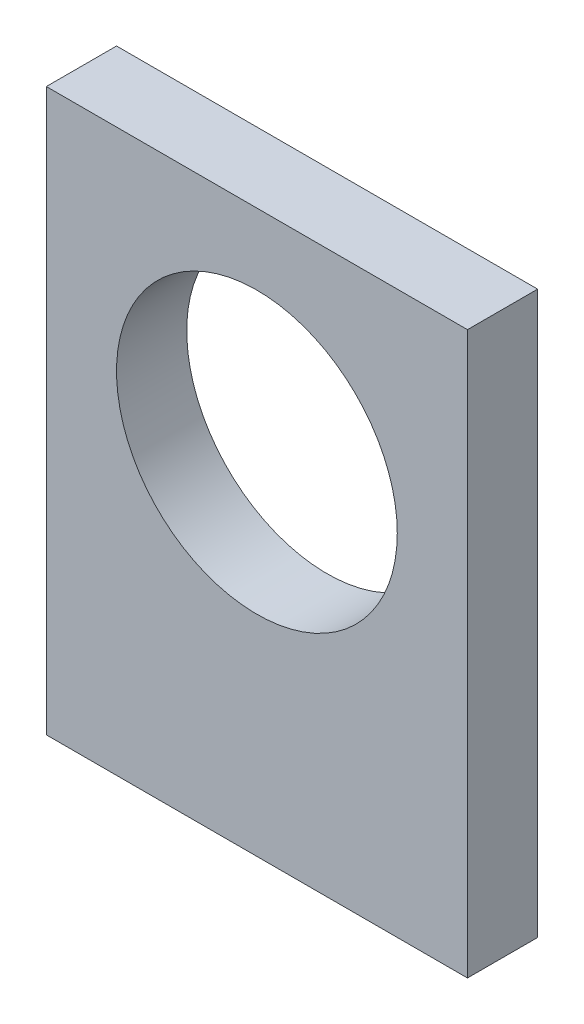
from build123d import *

# Parameters (mm, degrees)
SKETCH1_W           = 30
SKETCH1_H           = 40
SKETCH1_R           = 10
BOSS_EXTRUDE1_DEPTH = 5


with BuildPart() as part:
    # Sketch1 → Boss-Extrude1 (new body)
    with BuildSketch(Plane.XY):
        Rectangle(SKETCH1_W, SKETCH1_H)
        with Locations((0, 4.938800777)):
            Circle(SKETCH1_R, mode=Mode.SUBTRACT)
    extrude(amount=BOSS_EXTRUDE1_DEPTH)


solid = part.part
